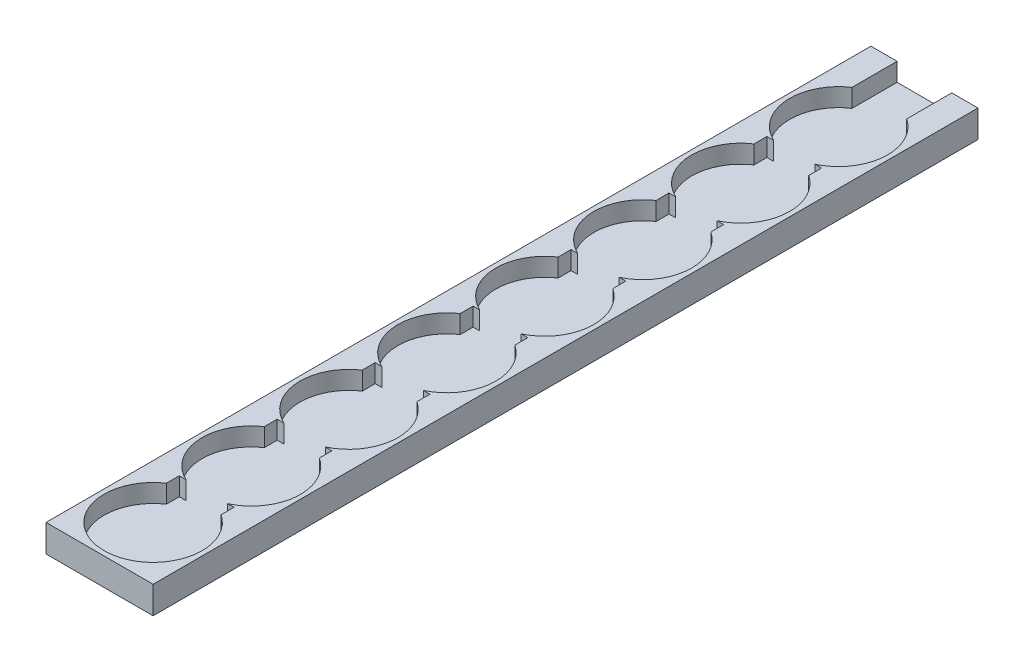
from build123d import *

# Parameters (mm, degrees)
SKETCH1_W           = 23.5
SKETCH1_H           = 181
BOSS_EXTRUDE1_DEPTH = 6
SKETCH2_R           = 10.75
CUT_EXTRUDE1_DEPTH  = 4
SKETCH3_W           = 12
SKETCH3_H           = 2.830218613
CUT_EXTRUDE2_DEPTH  = 4
SKETCH5_R           = 10.75
CUT_EXTRUDE5_DEPTH  = 4
LPATTERN1_COUNT     = 8
LPATTERN1_PITCH     = 21.49
SKETCH4_W           = 12
SKETCH4_H           = 4
CUT_EXTRUDE3_DEPTH  = 8.07


with BuildPart() as part:
    # Sketch1 → Boss-Extrude1 (new body)
    with BuildSketch(Plane(origin=(0, 0, 0), x_dir=(1, 0, 0), z_dir=(0, 1, 0))):
        with Locations((11.75, 90.5)):
            Rectangle(SKETCH1_W, SKETCH1_H)
    extrude(amount=-BOSS_EXTRUDE1_DEPTH)

    # Sketch2 → Cut-Extrude1 (cut)
    with BuildSketch(Plane(origin=(0, 0, 0), x_dir=(1, 0, 0), z_dir=(0, 1, 0))):
        with Locations((11.75, 11.75)):
            Circle(SKETCH2_R)
    cut_extrude1 = extrude(amount=-CUT_EXTRUDE1_DEPTH, mode=Mode.SUBTRACT)

    # Sketch3 → Cut-Extrude2 (cut)
    with BuildSketch(Plane(origin=(0, 0, 0), x_dir=(1, 0, 0), z_dir=(0, 1, 0))):
        with Locations((11.75, 22.084890694)):
            Rectangle(SKETCH3_W, SKETCH3_H)
    cut_extrude2 = extrude(amount=-CUT_EXTRUDE2_DEPTH, mode=Mode.SUBTRACT)

    # Sketch5 → Cut-Extrude5 (cut)
    with BuildSketch(Plane(origin=(0, 0, 0), x_dir=(1, 0, 0), z_dir=(0, 1, 0))):
        with Locations((11.845268795, 33.25)):
            Circle(SKETCH5_R)
    extrude(amount=-CUT_EXTRUDE5_DEPTH, mode=Mode.SUBTRACT)

    # LPattern1: Cut-Extrude1, Cut-Extrude2 ×8
    with Locations(*[(0, 0, -i * LPATTERN1_PITCH) for i in range(1, LPATTERN1_COUNT)]):
        add(cut_extrude1, mode=Mode.SUBTRACT)
        add(cut_extrude2, mode=Mode.SUBTRACT)

    # Sketch4 → Cut-Extrude3 (cut, through all)
    with BuildSketch(Plane.XY.offset(-173.93)):
        with Locations((11.75, -2)):
            Rectangle(SKETCH4_W, SKETCH4_H)
    extrude(amount=-CUT_EXTRUDE3_DEPTH, mode=Mode.SUBTRACT)


solid = part.part
